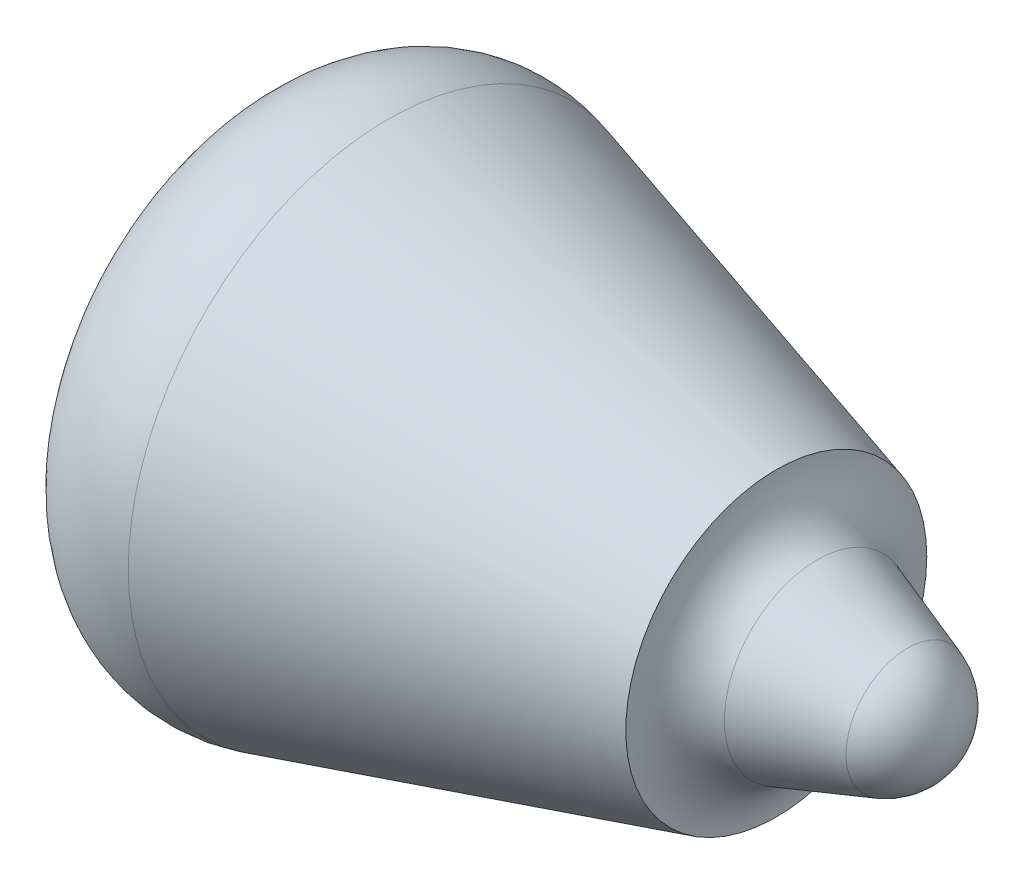
from build123d import *


with BuildPart() as part:
    # Croquis1 → Revolución1 (revolve)
    with BuildSketch(Plane.XY):
        with BuildLine():
            Line((0, 111), (0, 0))
            Line((0, 0), (522, 0))
            ThreePointArc((522, 0), (513.123486868, 27.809221049), (489.776967695, 45.333070604))
            Line((489.776967695, 45.333070604), (423.209092786, 68.500246309))
            ThreePointArc((423.209092786, 68.500246309), (401.321731062, 84.928855267), (393, 111))
            Line((393, 111), (106.834951456, 191.83665624))
            ThreePointArc((106.834951456, 191.83665624), (33.315366837, 177.985580248), (0, 111))
        make_face()
    revolve(axis=Axis((0, 0, 0), (1, 0, 0)))


solid = part.part
